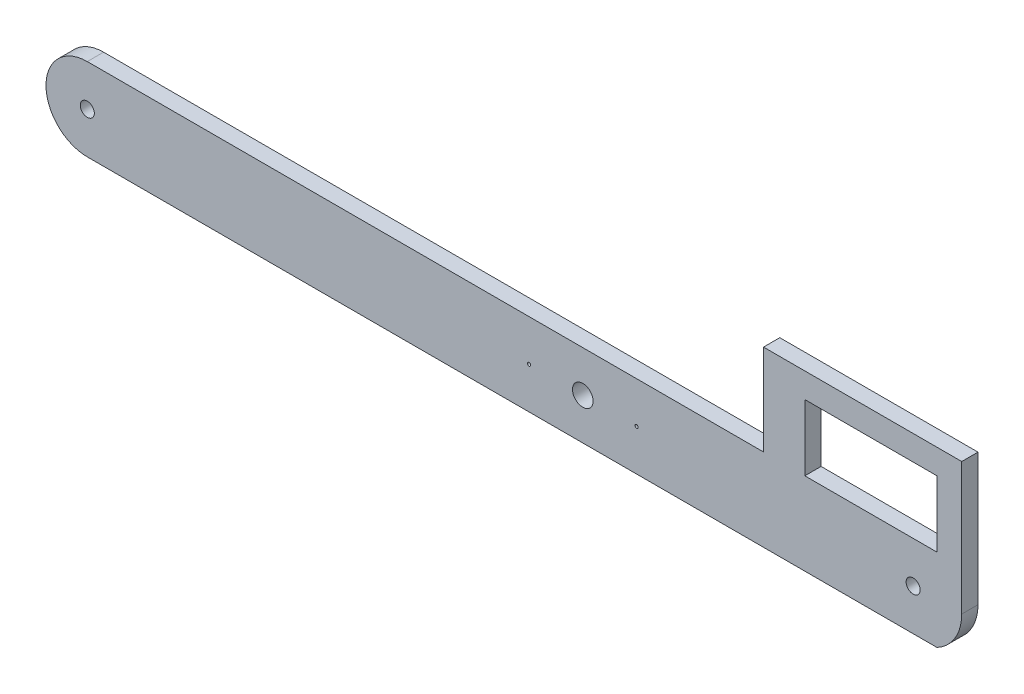
from build123d import *

# Parameters (mm, degrees)
SKETCH1_R           = 6.35
SKETCH1_R_2         = 3.175
SKETCH1_W           = 40.64
SKETCH1_H           = 20.32
BOSS_EXTRUDE1_DEPTH = 5.0038
SKETCH2_R           = 10.425848265
SKETCH2_R_2         = 2.159
SKETCH2_R_3         = 8.142875018
BOSS_EXTRUDE2_DEPTH = 5.0038
SKETCH3_R           = 0.50000027
CUT_EXTRUDE1_DEPTH  = 19.304


with BuildPart() as part:
    # Sketch1 → Boss-Extrude1 (new body)
    with BuildSketch(Plane.XY):
        with BuildLine():
            ThreePointArc((108.923032041, -12.7), (114.491880219, -7.405308906), (116.543032041, 0))
            Line((116.543032041, 0), (116.543032041, 40.64))
            Line((116.543032041, 40.64), (55.583032041, 40.64))
            Line((55.583032041, 40.64), (55.583032041, 12.7))
            Line((55.583032041, 12.7), (-152.4, 12.7))
            ThreePointArc((-152.4, 12.7), (-165.1, 0), (-152.4, -12.7))
            Line((-152.4, -12.7), (108.923032041, -12.7))
        make_face()
        with Locations((-152.4, 0)):
            Circle(SKETCH1_R, mode=Mode.SUBTRACT)
        Circle(SKETCH1_R_2, mode=Mode.SUBTRACT)
        with Locations((101.6, 0)):
            Circle(SKETCH1_R, mode=Mode.SUBTRACT)
        with Locations((88.603032041, 22.86)):
            Rectangle(SKETCH1_W, SKETCH1_H, mode=Mode.SUBTRACT)
    extrude(amount=BOSS_EXTRUDE1_DEPTH)

    # Sketch2 → Boss-Extrude2 (add)
    with BuildSketch(Plane.XY.offset(5.0038)):
        with Locations((-152.4, 0)):
            Circle(SKETCH2_R)
        with Locations((-152.4, 0)):
            Circle(SKETCH2_R_2, mode=Mode.SUBTRACT)
        with Locations((101.6, 0)):
            Circle(SKETCH2_R_3)
        with Locations((101.6, 0)):
            Circle(SKETCH2_R_2, mode=Mode.SUBTRACT)
    extrude(amount=-BOSS_EXTRUDE2_DEPTH)

    # Sketch3 → Cut-Extrude1 (cut)
    with BuildSketch(Plane(origin=(0, 0, 0), x_dir=(-1, 0, 0), z_dir=(0, 0, -1))):
        with Locations((16.5354, 0)):
            Circle(SKETCH3_R)
        with Locations((-16.5354, 0)):
            Circle(SKETCH3_R)
    extrude(amount=-CUT_EXTRUDE1_DEPTH, mode=Mode.SUBTRACT)


solid = part.part
